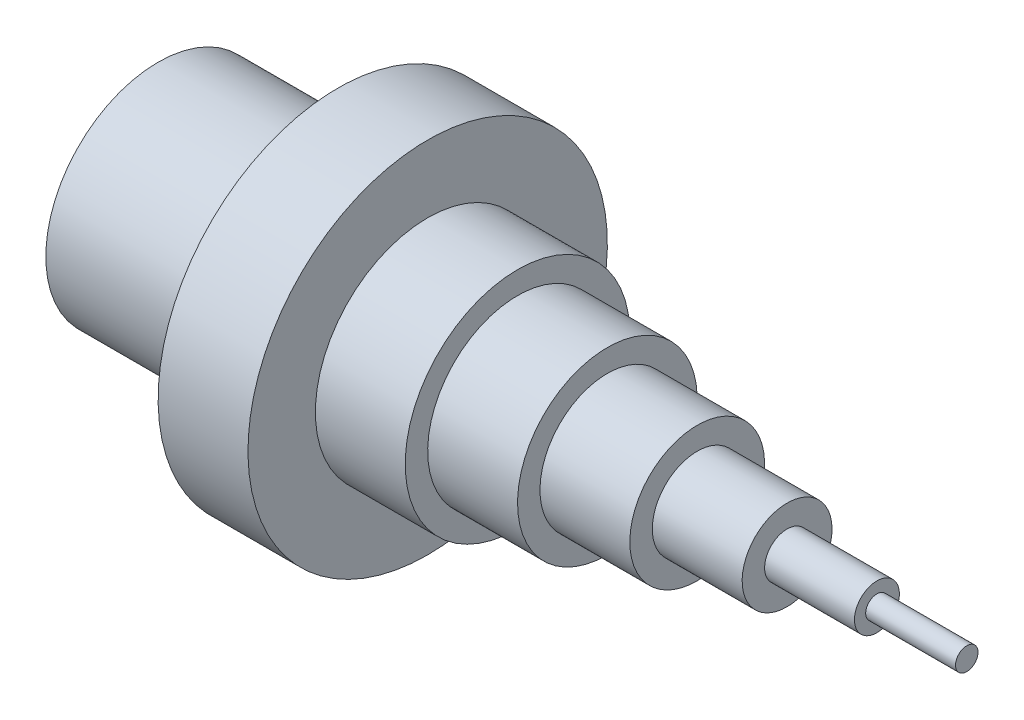
from build123d import *

# Parameters (mm, degrees)
SKETCH2_R          = 20
CUT_EXTRUDE2_DEPTH = 40


with BuildPart() as part:
    # Sketch1 → Revolve1 (revolve)
    with BuildSketch(Plane.XY, mode=Mode.PRIVATE) as revolve1_sk:
        Polygon((0, 0), (0, 25), (40, 25), (40, 40), (60, 40), (60, 25), (80, 25), (80, 20), (100, 20), (100, 15), (120, 15), (120, 10), (140, 10), (140, 5), (160, 5), (160, 2.5), (180, 2.5), (180, 0), align=None)
    revolve(revolve1_sk.sketch.rotate(Axis((-272.648237515, 0, 0), (1, 0, 0)), 180), axis=Axis((-272.648237515, 0, 0), (1, 0, 0)))  # turned: the seam where the file's is

    # Sketch2 → Cut-Extrude2 (cut)
    with BuildSketch(Plane.ZY):
        with Locations(Location((0, 0, 0), (0, 0, 270))):  # turned: the seam where the file's is
            Circle(SKETCH2_R)
    extrude(amount=-CUT_EXTRUDE2_DEPTH, mode=Mode.SUBTRACT)


solid = part.part
